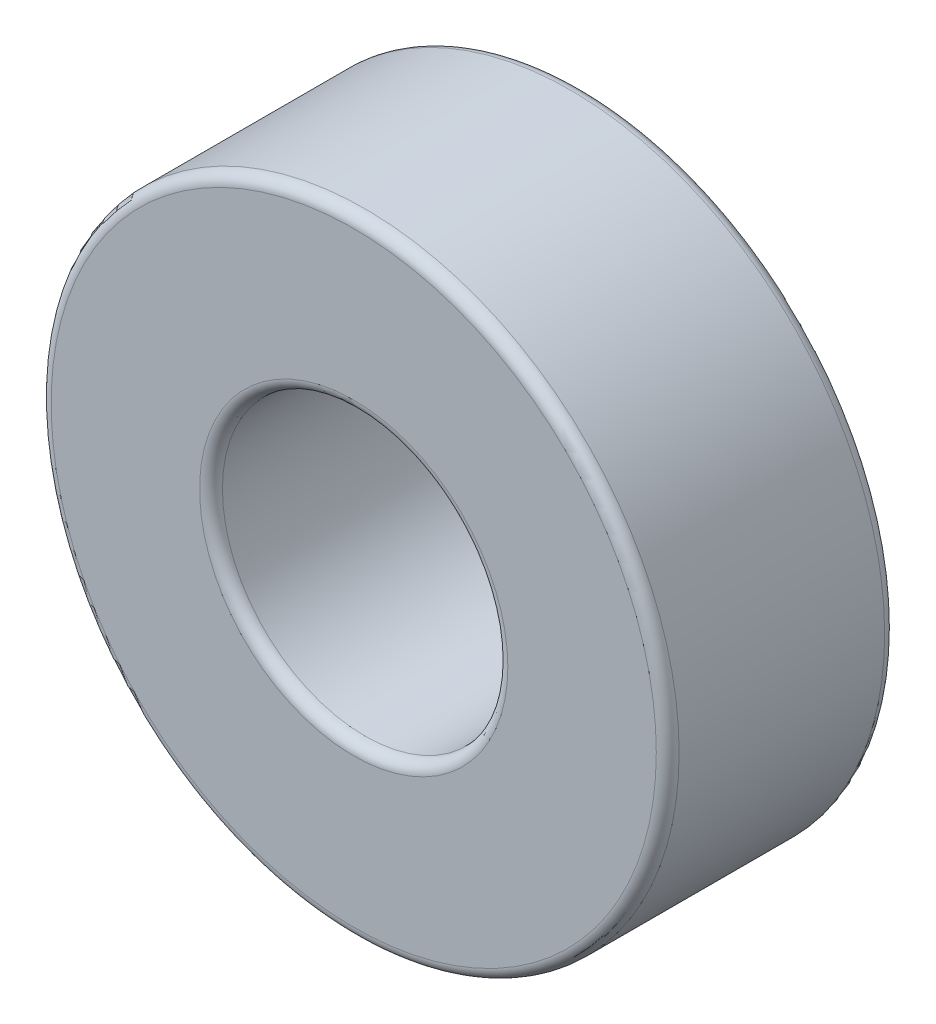
from build123d import *

# Parameters (mm, degrees)
SKETCH1_R           = 5.5
SKETCH1_R_2         = 2.5
BOSS_EXTRUDE1_DEPTH = 4
FILLET1_R           = 0.2


with BuildPart() as part:
    # Sketch1 → Boss-Extrude1 (new body)
    with BuildSketch(Plane.XY):
        Circle(SKETCH1_R)
        Circle(SKETCH1_R_2, mode=Mode.SUBTRACT)
    extrude(amount=BOSS_EXTRUDE1_DEPTH)

    # Fillet1
    fillet1_edges = [part.edges().sort_by_distance(p)[0] for p in [
        (-5.5, 0, 0),
        (-5.5, 0, 4),
        (-2.5, 0, 0),
        (-2.5, 0, 4),
    ]]
    fillet(fillet1_edges, radius=FILLET1_R)


solid = part.part
